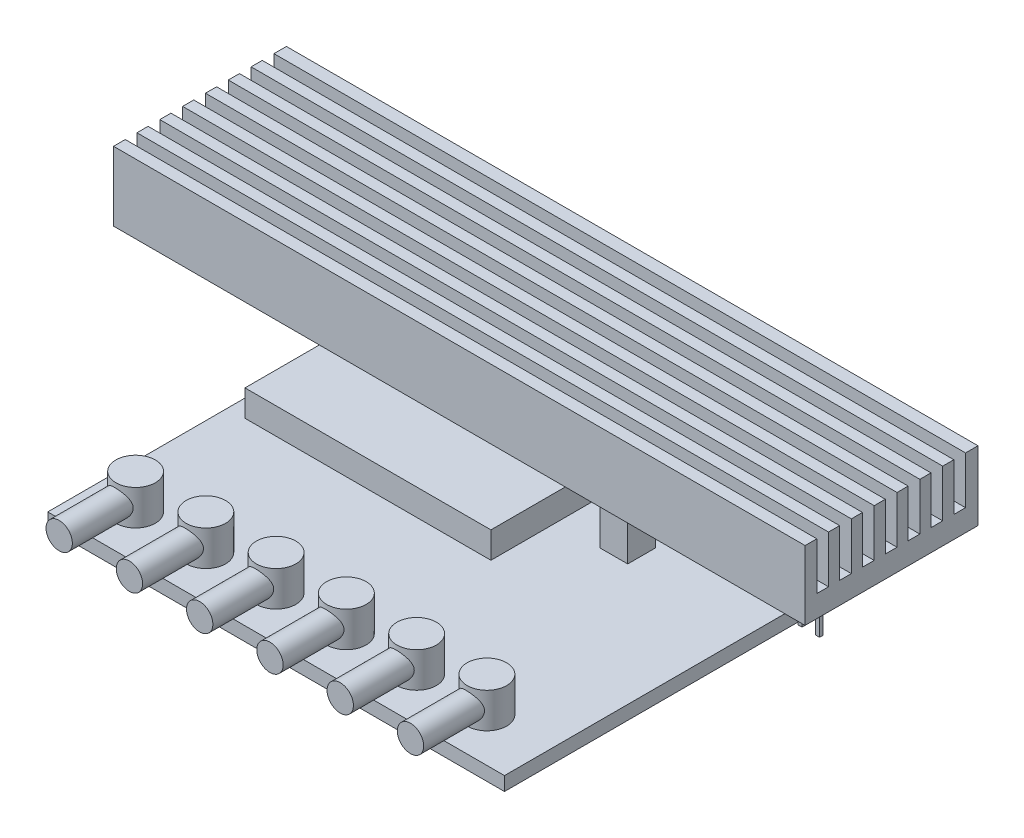
from build123d import *

# Parameters (mm, degrees)
SKETCH2_W                = 10
SKETCH2_H                = 10
BOSS_EXTRUDE1_DEPTH      = 4.5
SKETCH3_W                = 10
SKETCH3_H                = 1.3
BOSS_EXTRUDE2_DEPTH      = 6.4
SKETCH4_W                = 1.14
SKETCH4_H                = 0.5
BOSS_EXTRUDE3_DEPTH      = 3.75
SKETCH5_W                = 0.6
SKETCH5_H                = 0.5
BOSS_EXTRUDE4_DEPTH      = 10
BOSS_EXTRUDE4_TAPER      = 0.03
LPATTERN1_COUNT          = 2
LPATTERN1_PITCH          = 2.54
LPATTERN1_COL_COUNT      = 2
LPATTERN1_COL_PITCH      = 2.54
LPATTERN2_COUNT          = 4
LPATTERN2_PITCH          = 15.24
SKETCH6_W                = 66.04
SKETCH6_H                = 66.04
BOSS_EXTRUDE5_DEPTH      = 2
SKETCH7_R                = 2.8575
BOSS_EXTRUDE6_DEPTH      = 5.08
SKETCH10_R               = 1.905
BOSS_EXTRUDE7_DEPTH      = 8.128
BOSS_EXTRUDE7_DEPTH_BACK = 2.54
LPATTERN3_COUNT          = 6
LPATTERN3_PITCH          = 10.16
SKETCH11_W               = 35.56
SKETCH11_H               = 17.78
BOSS_EXTRUDE8_DEPTH      = 3.81
SKETCH12_W               = 4
SKETCH12_H               = 4
BOSS_EXTRUDE9_DEPTH      = 6.35
SKETCH14_W               = 100
SKETCH14_H               = 10
BOSS_EXTRUDE10_DEPTH     = 25
SKETCH15_W               = 1.693333334
SKETCH15_H               = 6.858
CUT_EXTRUDE1_DEPTH       = 101


with BuildPart() as part:
    # Sketch2 → Boss-Extrude1 (new body)
    with BuildSketch(Plane.XY):
        with Locations((0, 8.5)):
            Rectangle(SKETCH2_W, SKETCH2_H)
    extrude(amount=BOSS_EXTRUDE1_DEPTH)

    # Sketch4 → Boss-Extrude3 (add)
    with BuildSketch(Plane.XZ.offset(-3.5)):
        with Locations((0, 2.75)):
            Rectangle(SKETCH4_W, SKETCH4_H)
    boss_extrude3 = extrude(amount=BOSS_EXTRUDE3_DEPTH)

    # Sketch5 → Boss-Extrude4 (add)
    with BuildSketch(Plane.XZ.offset(0.25)):
        with Locations((0, 2.75)):
            Rectangle(SKETCH5_W, SKETCH5_H)
    boss_extrude4 = extrude(amount=BOSS_EXTRUDE4_DEPTH, taper=BOSS_EXTRUDE4_TAPER)

    # LPattern1: Boss-Extrude3, Boss-Extrude4 ×2
    with Locations(*[(i * LPATTERN1_PITCH, 0, 0) for i in range(1, LPATTERN1_COUNT)]):
        add(boss_extrude3)
        add(boss_extrude4)

    # LPattern1 col: Boss-Extrude3, Boss-Extrude4 ×2
    with Locations(*[(-i * LPATTERN1_COL_PITCH, 0, 0) for i in range(1, LPATTERN1_COL_COUNT)]):
        add(boss_extrude3)
        add(boss_extrude4)


with BuildPart() as body_2:
    # Sketch3 → Boss-Extrude2 (new body)
    with BuildSketch(Plane(origin=(0, 13.5, 0), x_dir=(1, 0, 0), z_dir=(0, 1, 0))):
        with Locations((0, -0.65)):
            Rectangle(SKETCH3_W, SKETCH3_H)
    extrude(amount=BOSS_EXTRUDE2_DEPTH)


with BuildPart() as lpattern2_1:
    # LPattern2: pattern copy
    add(body_2.part.moved(Location(Vector(1, 0, 0) * (1 * LPATTERN2_PITCH))))


with BuildPart() as lpattern2_2:
    # LPattern2: pattern copy
    add(body_2.part.moved(Location(Vector(1, 0, 0) * (2 * LPATTERN2_PITCH))))


with BuildPart() as lpattern2_3:
    # LPattern2: pattern copy
    add(body_2.part.moved(Location(Vector(1, 0, 0) * (3 * LPATTERN2_PITCH))))


with BuildPart() as lpattern2_4:
    # LPattern2: pattern copy
    add(part.part.moved(Location(Vector(1, 0, 0) * (1 * LPATTERN2_PITCH))))


with BuildPart() as lpattern2_5:
    # LPattern2: pattern copy
    add(part.part.moved(Location(Vector(1, 0, 0) * (2 * LPATTERN2_PITCH))))


with BuildPart() as lpattern2_6:
    # LPattern2: pattern copy
    add(part.part.moved(Location(Vector(1, 0, 0) * (3 * LPATTERN2_PITCH))))


with BuildPart() as body_9:
    # Sketch6 → Boss-Extrude5 (new body)
    with BuildSketch(Plane(origin=(0, 0, 0), x_dir=(1, 0, 0), z_dir=(0, 1, 0))):
        with Locations((20.32, -20.32)):
            Rectangle(SKETCH6_W, SKETCH6_H)
    extrude(amount=-BOSS_EXTRUDE5_DEPTH)

    # Sketch12 → Boss-Extrude9 (add)
    with BuildSketch(Plane(origin=(0, 0, 0), x_dir=(1, 0, 0), z_dir=(0, 1, 0))):
        with Locations((33.75, -15.93)):
            Rectangle(SKETCH12_W, SKETCH12_H)
    extrude(amount=BOSS_EXTRUDE9_DEPTH)


with BuildPart() as body_10:
    # Sketch7 → Boss-Extrude6 (new body)
    with BuildSketch(Plane(origin=(0, 0, 0), x_dir=(1, 0, 0), z_dir=(0, 1, 0))):
        with Locations((-6.35, 6.35)):
            Circle(SKETCH7_R)
    extrude(amount=BOSS_EXTRUDE6_DEPTH)

    # Sketch10 → Boss-Extrude7 (add, two sides)
    with BuildSketch(Plane(origin=(0, 0, -9.2075), x_dir=(-1, 0, 0), z_dir=(0, 0, -1))) as boss_extrude7_sk:
        with Locations((6.4135, 2.4892)):
            Circle(SKETCH10_R)
    extrude(amount=BOSS_EXTRUDE7_DEPTH)
    extrude(boss_extrude7_sk.sketch, amount=-BOSS_EXTRUDE7_DEPTH_BACK)


with BuildPart() as body_11:
    # Mirror1: mirrored copy
    add(body_10.part.mirror(Plane.XY.offset(20.32)))


with BuildPart() as lpattern3_1:
    # LPattern3: pattern copy
    add(body_10.part.moved(Location(Vector(1, 0, 0) * (1 * LPATTERN3_PITCH))))


with BuildPart() as lpattern3_2:
    # LPattern3: pattern copy
    add(body_10.part.moved(Location(Vector(1, 0, 0) * (2 * LPATTERN3_PITCH))))


with BuildPart() as lpattern3_3:
    # LPattern3: pattern copy
    add(body_10.part.moved(Location(Vector(1, 0, 0) * (3 * LPATTERN3_PITCH))))


with BuildPart() as lpattern3_4:
    # LPattern3: pattern copy
    add(body_10.part.moved(Location(Vector(1, 0, 0) * (4 * LPATTERN3_PITCH))))


with BuildPart() as lpattern3_5:
    # LPattern3: pattern copy
    add(body_10.part.moved(Location(Vector(1, 0, 0) * (5 * LPATTERN3_PITCH))))


with BuildPart() as lpattern3_6:
    # LPattern3: pattern copy
    add(body_11.part.moved(Location(Vector(1, 0, 0) * (1 * LPATTERN3_PITCH))))


with BuildPart() as lpattern3_7:
    # LPattern3: pattern copy
    add(body_11.part.moved(Location(Vector(1, 0, 0) * (2 * LPATTERN3_PITCH))))


with BuildPart() as lpattern3_8:
    # LPattern3: pattern copy
    add(body_11.part.moved(Location(Vector(1, 0, 0) * (3 * LPATTERN3_PITCH))))


with BuildPart() as lpattern3_9:
    # LPattern3: pattern copy
    add(body_11.part.moved(Location(Vector(1, 0, 0) * (4 * LPATTERN3_PITCH))))


with BuildPart() as lpattern3_10:
    # LPattern3: pattern copy
    add(body_11.part.moved(Location(Vector(1, 0, 0) * (5 * LPATTERN3_PITCH))))


with BuildPart() as body_22:
    # Sketch11 → Boss-Extrude8 (new body)
    with BuildSketch(Plane(origin=(0, 0, 0), x_dir=(1, 0, 0), z_dir=(0, 1, 0))):
        with Locations((7.62, -18.47)):
            Rectangle(SKETCH11_W, SKETCH11_H)
    extrude(amount=BOSS_EXTRUDE8_DEPTH)


with BuildPart() as body_23:
    # Sketch14 → Boss-Extrude10 (new body)
    with BuildSketch(Plane(origin=(0, 0, 1.3), x_dir=(-1, 0, 0), z_dir=(0, 0, -1))):
        with Locations((-19.77, 18.5)):
            Rectangle(SKETCH14_W, SKETCH14_H)
    extrude(amount=-BOSS_EXTRUDE10_DEPTH)

    # Sketch15 → Cut-Extrude1 (cut, through all)
    with BuildSketch(Plane(origin=(69.77, 0, 0), x_dir=(0, 0, -1), z_dir=(1, 0, 0))):
        with Locations((-23.76, 20.071)):
            Rectangle(SKETCH15_W, SKETCH15_H)
        with Locations((-20.458, 20.071)):
            Rectangle(SKETCH15_W, SKETCH15_H)
        with Locations((-17.156, 20.071)):
            Rectangle(SKETCH15_W, SKETCH15_H)
        with Locations((-13.854, 20.071)):
            Rectangle(SKETCH15_W, SKETCH15_H)
        with Locations((-10.552, 20.071)):
            Rectangle(SKETCH15_W, SKETCH15_H)
        with Locations((-7.25, 20.071)):
            Rectangle(SKETCH15_W, SKETCH15_H)
        with Locations((-3.948, 20.071)):
            Rectangle(SKETCH15_W, SKETCH15_H)
    extrude(amount=-CUT_EXTRUDE1_DEPTH, mode=Mode.SUBTRACT)


solid = Compound([part.part, body_2.part, lpattern2_1.part, lpattern2_2.part, lpattern2_3.part, lpattern2_4.part, lpattern2_5.part, lpattern2_6.part, body_9.part, body_10.part, body_11.part, lpattern3_1.part, lpattern3_2.part, lpattern3_3.part, lpattern3_4.part, lpattern3_5.part, lpattern3_6.part, lpattern3_7.part, lpattern3_8.part, lpattern3_9.part, lpattern3_10.part, body_22.part, body_23.part])
